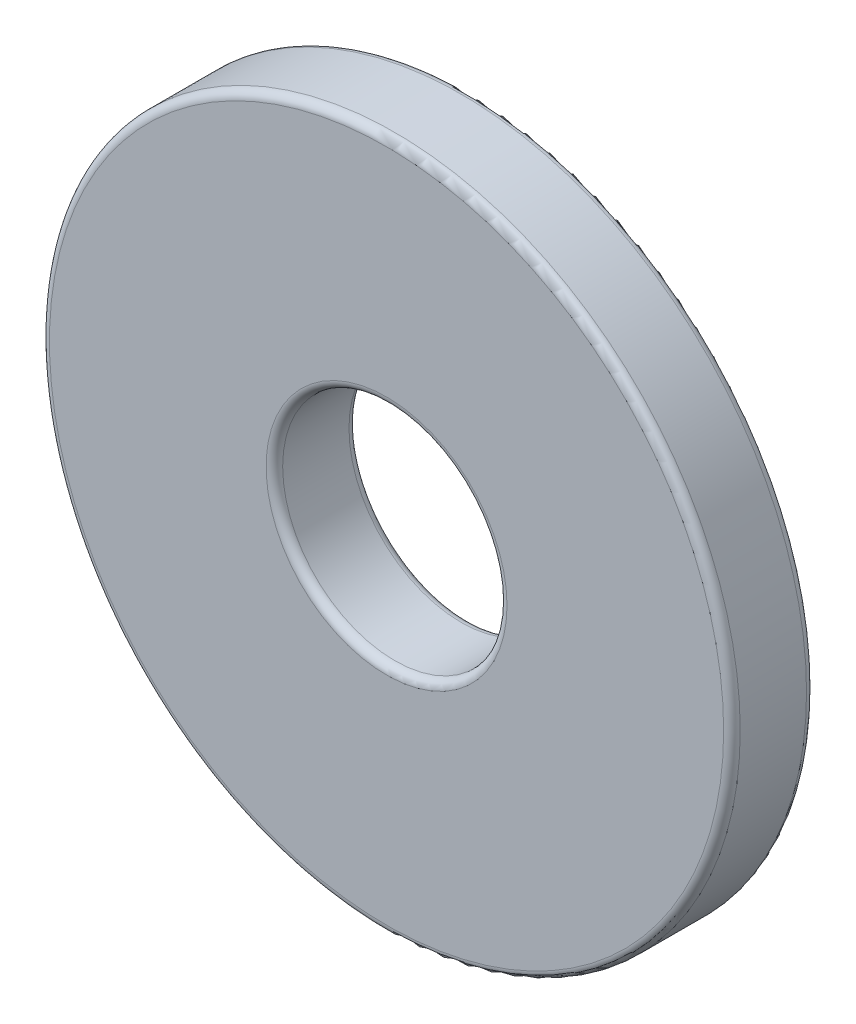
from build123d import *

# Parameters (mm, degrees)
BOSS_EXTRUDE1_START = 0.9525
SKETCH3_R           = 7.9375
SKETCH3_R_2         = 2.5781
BOSS_EXTRUDE1_DEPTH = 1.905
FILLET1_R           = 0.1905


with BuildPart() as part:
    # Sketch3 → Boss-Extrude1 (new body)
    with BuildSketch(Plane.XY.offset(BOSS_EXTRUDE1_START)):
        Circle(SKETCH3_R)
        Circle(SKETCH3_R_2, mode=Mode.SUBTRACT)
    extrude(amount=-BOSS_EXTRUDE1_DEPTH)

    # Fillet1
    fillet1_edges = [part.edges().sort_by_distance(p)[0] for p in [
        (-7.9375, 0, 0.9525),
        (-7.9375, 0, -0.9525),
        (-2.5781, 0, -0.9525),
        (-2.5781, 0, 0.9525),
    ]]
    fillet(fillet1_edges, radius=FILLET1_R)


solid = part.part
